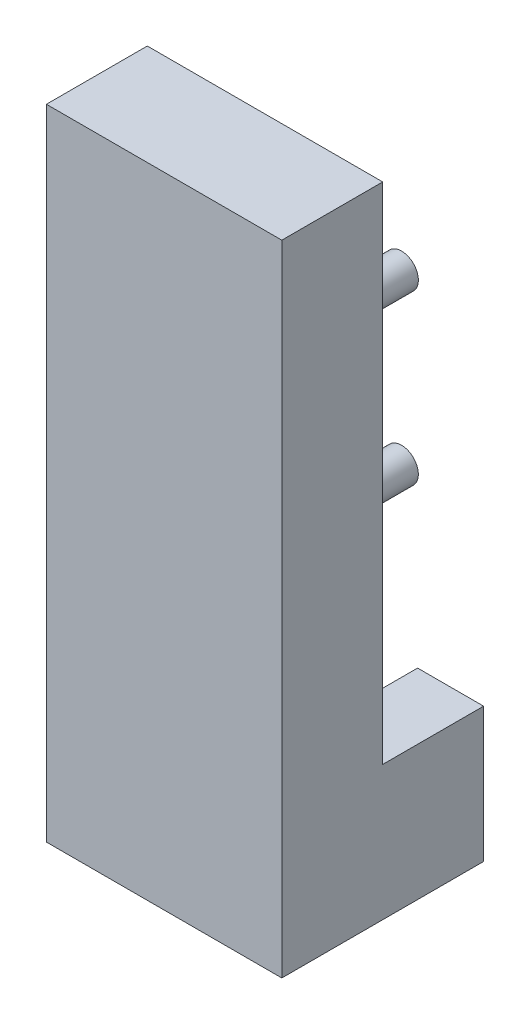
from build123d import *

# Parameters (mm, degrees)
SKETCH1_W           = 44.45
SKETCH1_H           = 120.65
BOSS_EXTRUDE1_DEPTH = 19.05
BOSS_EXTRUDE2_DEPTH = 19.05
SKETCH2_4_R         = 3.175
BOSS_EXTRUDE3_DEPTH = 12.7


with BuildPart() as part:
    # Sketch1 → Boss-Extrude1 (new body)
    with BuildSketch(Plane.XY):
        with Locations((22.225, 60.325)):
            Rectangle(SKETCH1_W, SKETCH1_H)
    extrude(amount=BOSS_EXTRUDE1_DEPTH)

    # Sketch2 → Boss-Extrude2 (add)
    with BuildSketch(Plane(origin=(0, 0, 0), x_dir=(-1, 0, 0), z_dir=(0, 0, -1))):
        with BuildLine():
            ThreePointArc((-26.281784125, 16.521928603), (-30.437065172, 20.123672226), (-31.986027055, 25.4))
            Line((-31.986027055, 25.4), (-44.45, 25.4))
            Line((-44.45, 25.4), (-44.45, 0))
            Line((-44.45, 0), (-26.281784125, 0))
            Line((-26.281784125, 0), (-26.281784125, 16.521928603))
        make_face()
        with BuildLine():
            Line((0, 25.4), (-12.463972945, 25.4))
            ThreePointArc((-12.463972945, 25.4), (-14.012934828, 20.123672226), (-18.168215875, 16.521928603))
            Line((-18.168215875, 16.521928603), (-18.168215875, 0))
            Line((-18.168215875, 0), (0, 0))
            Line((0, 0), (0, 25.4))
        make_face()
    extrude(amount=BOSS_EXTRUDE2_DEPTH)

    # Sketch2_4 → Boss-Extrude3 (add)
    with BuildSketch(Plane(origin=(0, 0, 0), x_dir=(-1, 0, 0), z_dir=(0, 0, -1))):
        with Locations((-35.306, 95.25)):
            Circle(SKETCH2_4_R)
        with Locations((-35.306, 63.5)):
            Circle(SKETCH2_4_R)
        with Locations((-9.144, 95.25)):
            Circle(SKETCH2_4_R)
        with Locations((-9.144, 63.5)):
            Circle(SKETCH2_4_R)
    extrude(amount=BOSS_EXTRUDE3_DEPTH)


solid = part.part
